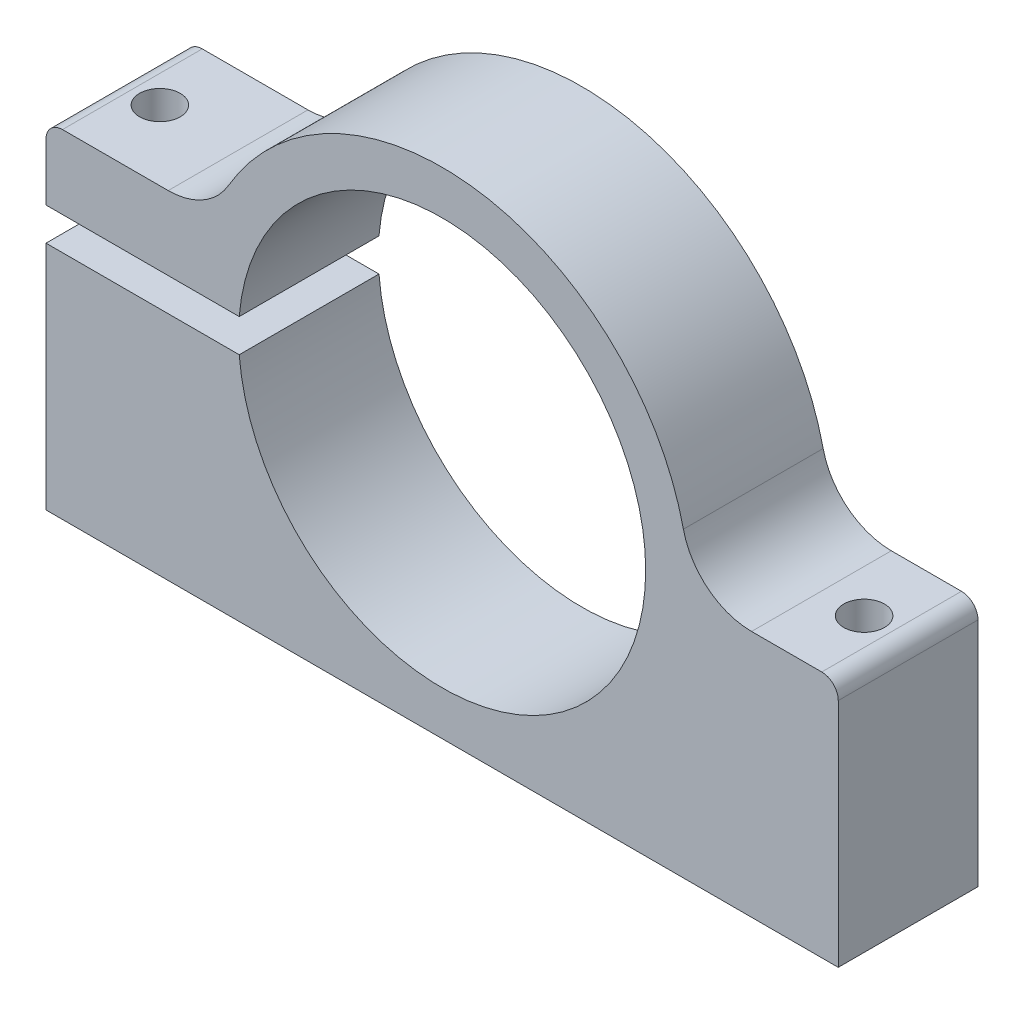
from build123d import *

# Parameters (mm, degrees)
EXTRUDE1_DEPTH     = 12.7
SKETCH2_R          = 18.5
CUT_EXTRUDE1_DEPTH = 13.7
SKETCH4_W          = 3.990810773
SKETCH4_H          = 3
CUT_EXTRUDE2_DEPTH = 13.7
SKETCH5_R          = 1.85
CUT_EXTRUDE3_DEPTH = 31.691017566
SKETCH6_R          = 1.85
CUT_EXTRUDE4_DEPTH = 23.5
FILLET2_R          = 6.35
FILLET3_R          = 6.35
FILLET6_R          = 1.5
FILLET7_R          = 1.5


with BuildPart() as part:
    # Sketch1 → Extrude1 (new body)
    with BuildSketch(Plane.XY):
        with BuildLine():
            Line((-22.429899688, -1.5), (-36, -1.5))
            Line((-36, -1.5), (-36, -22.5))
            Line((-36, -22.5), (36, -22.5))
            Line((36, -22.5), (36, 0))
            Line((36, 0), (22.48, 0))
            ThreePointArc((22.48, 0), (4.167763746, 22.090272641), (-20.93460368, 8.191017566))
            Line((-20.93460368, 8.191017566), (-36, 8.191017566))
            Line((-36, 8.191017566), (-36, 1.5))
            Line((-36, 1.5), (-22.429899688, 1.5))
            Line((-22.429899688, 1.5), (-22.429899688, -1.5))
        make_face()
    extrude(amount=-EXTRUDE1_DEPTH)

    # Sketch2 → Cut-Extrude1 (cut, through all)
    with BuildSketch(Plane.XY):
        Circle(SKETCH2_R)
    extrude(amount=-CUT_EXTRUDE1_DEPTH, mode=Mode.SUBTRACT)

    # Sketch4 → Cut-Extrude2 (cut, through all)
    with BuildSketch(Plane.XY):
        with Locations((-20.434494302, 0)):
            Rectangle(SKETCH4_W, SKETCH4_H)
    extrude(amount=-CUT_EXTRUDE2_DEPTH, mode=Mode.SUBTRACT)

    # Sketch5 → Cut-Extrude3 (cut, through all)
    with BuildSketch(Plane(origin=(0, 8.191017566, 0), x_dir=(1, 0, 0), z_dir=(0, 1, 0))):
        with Locations((-32, 6.35)):
            Circle(SKETCH5_R)
    extrude(amount=-CUT_EXTRUDE3_DEPTH, mode=Mode.SUBTRACT)

    # Sketch6 → Cut-Extrude4 (cut, through all)
    with BuildSketch(Plane(origin=(0, 0, 0), x_dir=(1, 0, 0), z_dir=(0, 1, 0))):
        with Locations((32, 6.35)):
            Circle(SKETCH6_R)
    extrude(amount=-CUT_EXTRUDE4_DEPTH, mode=Mode.SUBTRACT)

    # Fillet2
    fillet2_edges = [part.edges().sort_by_distance(p)[0] for p in [
        (22.48, 0, -6.35),
    ]]
    fillet(fillet2_edges, radius=FILLET2_R)

    # Fillet3
    fillet3_edges = [part.edges().sort_by_distance(p)[0] for p in [
        (-20.93460368, 8.191017566, -6.35),
    ]]
    fillet(fillet3_edges, radius=FILLET3_R)

    # Fillet6
    fillet6_edges = [part.edges().sort_by_distance(p)[0] for p in [
        (36, 0, -6.35),
    ]]
    fillet(fillet6_edges, radius=FILLET6_R)

    # Fillet7
    fillet7_edges = [part.edges().sort_by_distance(p)[0] for p in [
        (-36, 8.191017566, -6.35),
    ]]
    fillet(fillet7_edges, radius=FILLET7_R)


solid = part.part
